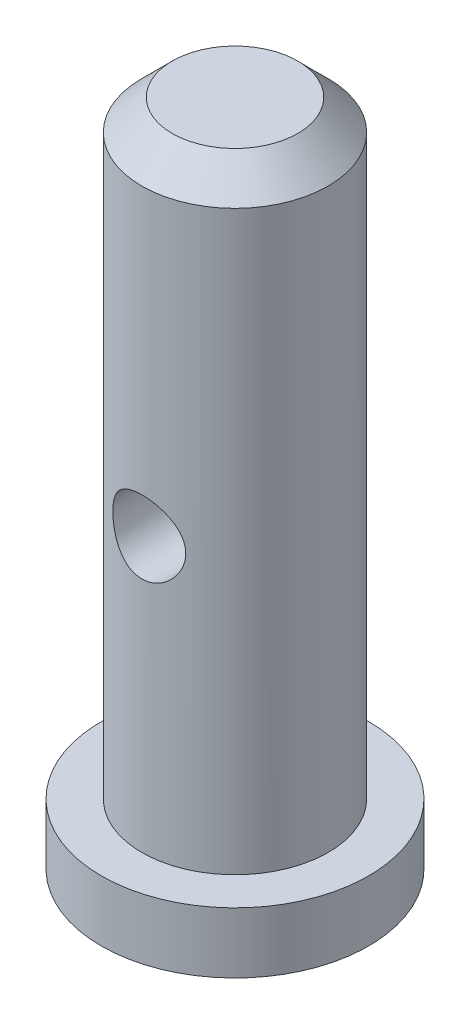
from build123d import *

# Parameters (mm, degrees)
CHAMFER1_SIZE           = 0.75
SKETCH2_R               = 0.9
CUT_EXTRUDE1_DEPTH      = 4.3
CUT_EXTRUDE1_DEPTH_BACK = 4.3


with BuildPart() as part:
    # Sketch1 → Revolve1 (revolve)
    with BuildSketch(Plane.XY):
        Polygon((0, 16.5), (2.3, 16.5), (2.3, 1.5), (3.3, 1.5), (3.3, 0), (0, 0), align=None)
    revolve(axis=Axis((0, 0, 0), (0, 1, 0)))

    # Chamfer1
    chamfer1_edges = [part.edges().sort_by_distance(p)[0] for p in [
        (-2.3, 16.5, 0),
    ]]
    chamfer(chamfer1_edges, length=CHAMFER1_SIZE)

    # Sketch2 → Cut-Extrude1 (cut, two sides)
    with BuildSketch(Plane.XY) as cut_extrude1_sk:
        with Locations((0, 8.25)):
            Circle(SKETCH2_R)
    extrude(amount=CUT_EXTRUDE1_DEPTH, mode=Mode.SUBTRACT)
    extrude(cut_extrude1_sk.sketch, amount=-CUT_EXTRUDE1_DEPTH_BACK, mode=Mode.SUBTRACT)


solid = part.part
